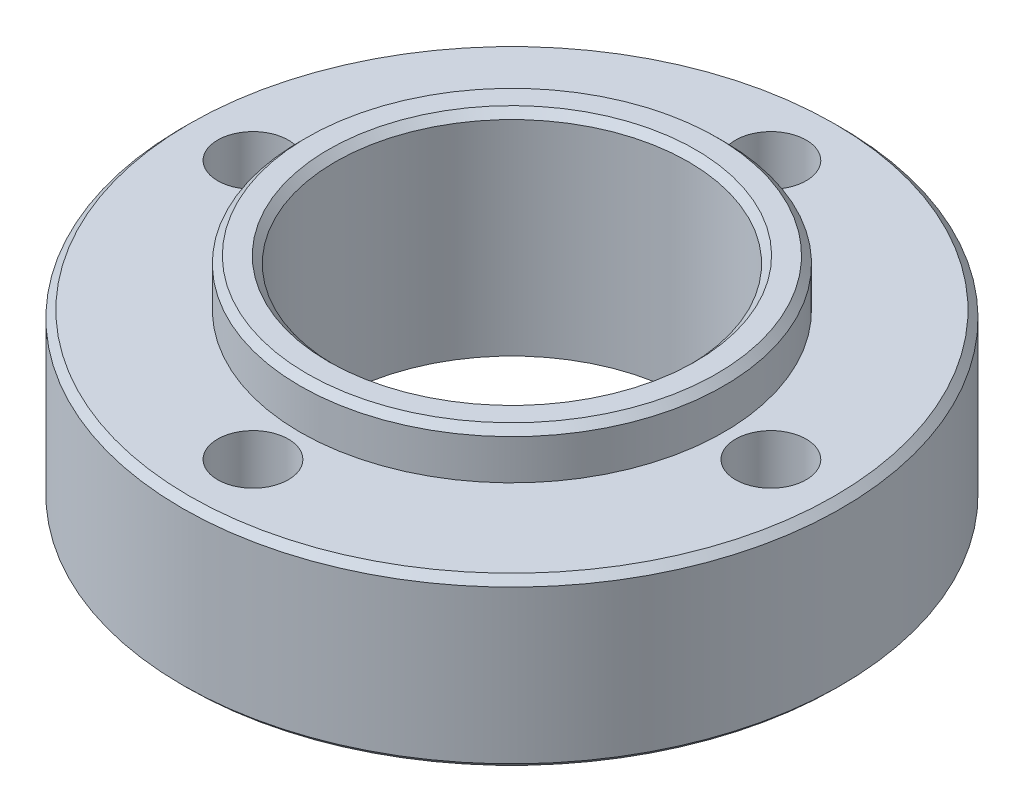
from build123d import *

# Parameters (mm, degrees)
SKETCH_1_R      = 14
SKETCH_1_R_2    = 1.5
SKETCH_1_R_3    = 7.5
EXTRUDE_1_DEPTH = 7
SKETCH_1_3_R    = 9
SKETCH_1_3_R_2  = 7.5
EXTRUDE_2_DEPTH = 9
CHAMFER_1_SIZE  = 0.3
CHAMFER_4_SIZE  = 0.2


with BuildPart() as part:
    # Эскиз1 → Бобышка-Вытянуть1 (new body)
    with BuildSketch(Plane(origin=(0, 0, 0), x_dir=(1, 0, 0), z_dir=(0, 1, 0))):
        Circle(SKETCH_1_R)
        with Locations((-11, 0)):
            Circle(SKETCH_1_R_2, mode=Mode.SUBTRACT)
        with Locations((0, -11)):
            Circle(SKETCH_1_R_2, mode=Mode.SUBTRACT)
        with Locations((11, 0)):
            Circle(SKETCH_1_R_2, mode=Mode.SUBTRACT)
        with Locations((0, 11)):
            Circle(SKETCH_1_R_2, mode=Mode.SUBTRACT)
        Circle(SKETCH_1_R_3, mode=Mode.SUBTRACT)
    extrude(amount=EXTRUDE_1_DEPTH)

    # Эскиз1<3> → Бобышка-Вытянуть2 (add)
    with BuildSketch(Plane(origin=(0, 0, 0), x_dir=(1, 0, 0), z_dir=(0, 1, 0))):
        Circle(SKETCH_1_3_R)
        Circle(SKETCH_1_3_R_2, mode=Mode.SUBTRACT)
    extrude(amount=EXTRUDE_2_DEPTH)

    # Фаска1
    chamfer_1_edges = [part.edges().sort_by_distance(p)[0] for p in [
        (-9, 9, 0),
        (-14, 7, 0),
        (-7.5, 9, 0),
    ]]
    chamfer(chamfer_1_edges, length=CHAMFER_1_SIZE)

    # Фаска4
    chamfer_4_edges = [part.edges().sort_by_distance(p)[0] for p in [
        (-14, 0, 0),
    ]]
    chamfer(chamfer_4_edges, length=CHAMFER_4_SIZE)


solid = part.part
